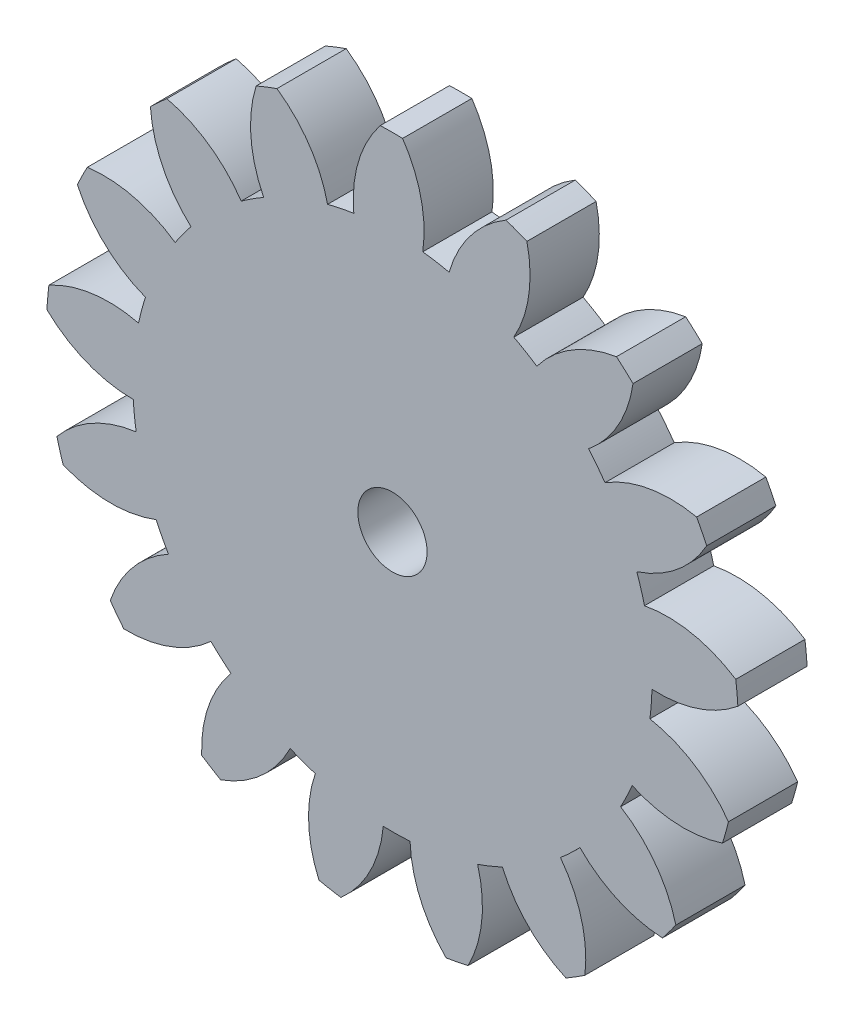
from build123d import *

# Parameters (mm, degrees)
SKIZZE1_R                       = 20
AUFSATZ_LINEAR_AUSTRAGEN1_DEPTH = 4
SCHNITT_LINEAR_AUSTRAGEN1_REACH = 6
SKIZZE2_R                       = 2
SCHNITT_LINEAR_AUSTRAGEN2_DEPTH = 4
KREISMUSTER1_COUNT              = 17


with BuildPart() as part:
    # Skizze1 → Aufsatz-Linear austragen1 (new body)
    with BuildSketch(Plane.XY):
        Circle(SKIZZE1_R)
    extrude(amount=AUFSATZ_LINEAR_AUSTRAGEN1_DEPTH)

    # Skizze2 → Schnitt-Linear austragen1 (cut, up to next)
    with BuildSketch(Plane.XY.offset(4), mode=Mode.PRIVATE) as schnitt_linear_austragen1_sk1:
        Circle(SKIZZE2_R)
    schnitt_linear_austragen1_tool1 = extrude(schnitt_linear_austragen1_sk1.sketch, amount=-SCHNITT_LINEAR_AUSTRAGEN1_REACH, mode=Mode.PRIVATE) & part.part
    add(schnitt_linear_austragen1_tool1.solids().sort_by_distance((0, 0, 4))[0], mode=Mode.SUBTRACT)

    # Skizze3 → Schnitt-Linear austragen2 (cut)
    with BuildSketch(Plane.XY.offset(4)):
        with BuildLine():
            ThreePointArc((0.586774522, 19.991390538), (1.647430818, 17.553771601), (1.751244892, 14.897420627))
            ThreePointArc((1.751244892, 14.897420627), (2.516627793, 14.787379232), (3.275322949, 14.638041521))
            ThreePointArc((3.275322949, 14.638041521), (4.506718961, 17.083727504), (6.562201755, 18.892789845))
            ThreePointArc((6.562201755, 18.892789845), (3.616448026, 19.670315292), (0.586774522, 19.991390538))
        make_face()
    schnitt_linear_austragen2 = extrude(amount=-SCHNITT_LINEAR_AUSTRAGEN2_DEPTH, mode=Mode.SUBTRACT)

    # Kreismuster1: Schnitt-Linear austragen2 ×17 about axis
    kreismuster1_axis = Axis((0, 0, 0), (0, 0, 1))
    for i in range(1, KREISMUSTER1_COUNT):
        add(schnitt_linear_austragen2.rotate(kreismuster1_axis, i * 360 / KREISMUSTER1_COUNT), mode=Mode.SUBTRACT)


solid = part.part
